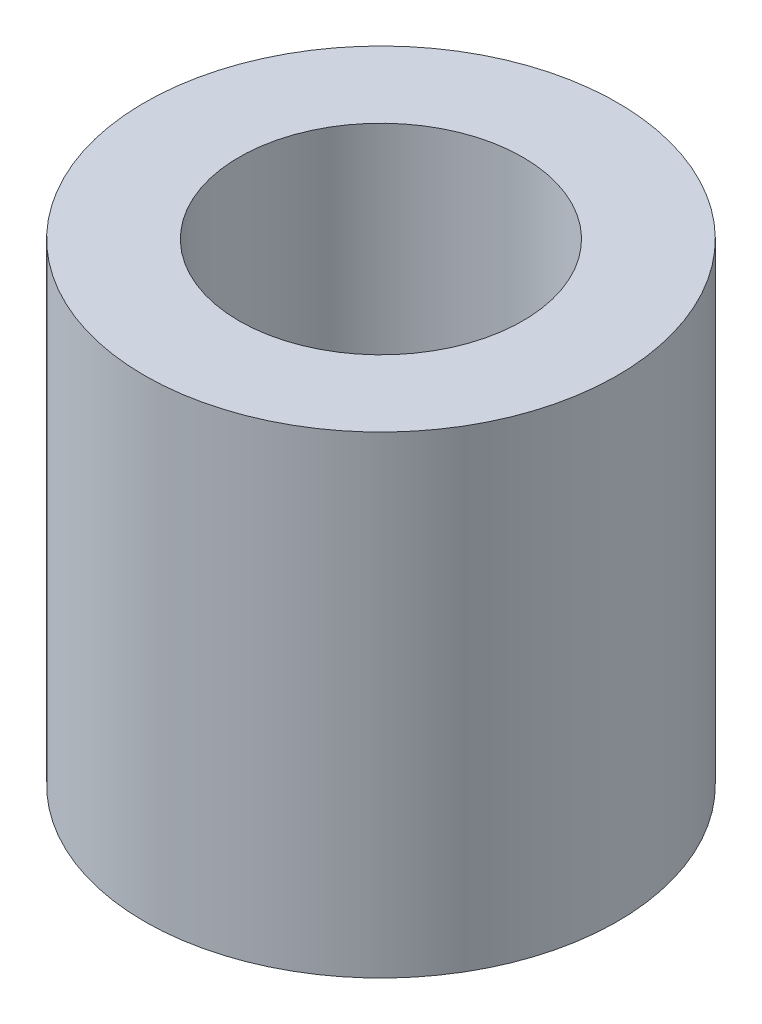
from build123d import *

# Parameters (mm, degrees)
SKETCH_1_R      = 2.5
SKETCH_1_R_2    = 1.5
EXTRUDE_1_DEPTH = 5


with BuildPart() as part:
    # 草图1 → 凸台-拉伸1 (new body)
    with BuildSketch(Plane(origin=(0, 0, 0), x_dir=(1, 0, 0), z_dir=(0, 1, 0))):
        Circle(SKETCH_1_R)
        Circle(SKETCH_1_R_2, mode=Mode.SUBTRACT)
    extrude(amount=EXTRUDE_1_DEPTH)


solid = part.part
